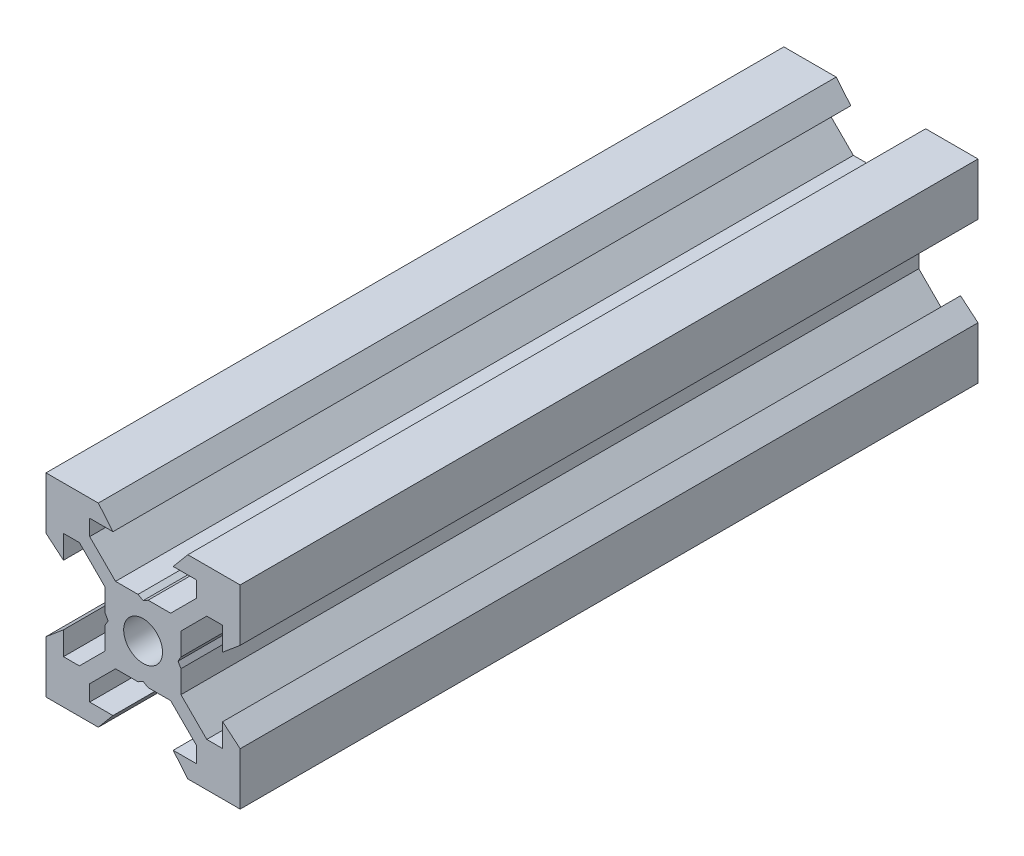
from build123d import *

# Parameters (mm, degrees)
SKETCH1_R           = 2
BOSS_EXTRUDE1_DEPTH = 38


with BuildPart() as part:
    # Sketch1 → Boss-Extrude1 (new body, symmetric)
    with BuildSketch(Plane.XY):
        Polygon((10, 10), (10, 4.610379336), (8.2, 3.1), (8.2, 5.5), (6.560660172, 5.5), (3.9, 2.839339828), (3.9, 0.519615242), (3.6, 0), (3.9, -0.519615242), (3.9, -2.839339828), (6.560660172, -5.5), (8.2, -5.5), (8.2, -3.1), (10, -4.610379336), (10, -10), (4.610379336, -10), (3.1, -8.2), (5.5, -8.2), (5.5, -6.560660172), (2.839339828, -3.9), (0.519615242, -3.9), (0, -3.6), (-0.519615242, -3.9), (-2.839339828, -3.9), (-5.5, -6.560660172), (-5.5, -8.2), (-3.1, -8.2), (-4.610379336, -10), (-10, -10), (-10, -4.610379336), (-8.2, -3.1), (-8.2, -5.5), (-6.560660172, -5.5), (-3.9, -2.839339828), (-3.9, -0.519615242), (-3.6, 0), (-3.9, 0.519615242), (-3.9, 2.839339828), (-6.560660172, 5.5), (-8.2, 5.5), (-8.2, 3.1), (-10, 4.610379336), (-10, 10), (-4.610379336, 10), (-3.1, 8.2), (-5.5, 8.2), (-5.5, 6.560660172), (-2.839339828, 3.9), (-0.519615242, 3.9), (0, 3.6), (0.519615242, 3.9), (2.839339828, 3.9), (5.5, 6.560660172), (5.5, 8.2), (3.1, 8.2), (4.610379336, 10), align=None)
        Circle(SKETCH1_R, mode=Mode.SUBTRACT)
    extrude(amount=BOSS_EXTRUDE1_DEPTH, both=True)


solid = part.part
